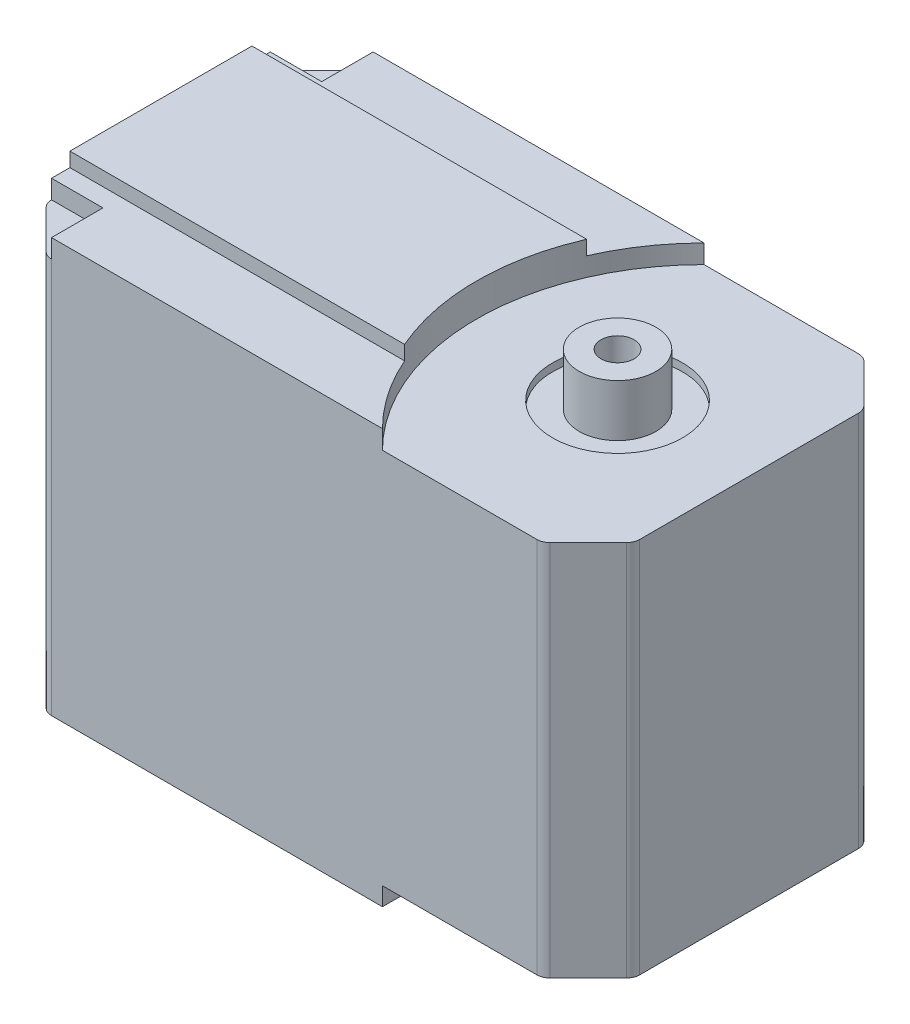
from build123d import *

# Parameters (mm, degrees)
IZIM1_W                      = 45.23
IZIM1_H                      = 24.73
Y_KSEKLIK_EKSTR_ZYON1_DEPTH  = 29
PAH1_SIZE                    = 3.54
RADYUS1_R                    = 1
IZIM3_R                      = 5
KES_EKSTR_ZYON1_DEPTH        = 0.6
IZIM4_R                      = 2.95
Y_KSEKLIK_EKSTR_ZYON2_DEPTH  = 4
IZIM5_R                      = 1.275
KES_EKSTR_ZYON2_DEPTH        = 8
Y_KSEKLIK_EKSTR_ZYON3_DEPTH  = 1.44
Y_KSEKLIK_EKSTR_ZYON4_DEPTH  = 1.1
IZIM8_R                      = 3
IZIM8_R_2                    = 1.2
Y_KSEKLIK_EKSTR_ZYON5_DEPTH  = 4.1
Y_KSEKLIK_EKSTR_ZYON6_DEPTH  = 1.4
IZIM10_W                     = 10
IZIM10_H                     = 18.55
Y_KSEKLIK_EKSTR_ZYON7_DEPTH  = 1.83
Y_KSEKLIK_EKSTR_ZYON8_DEPTH  = 18.55
IZIM12_W                     = 4.8
IZIM12_H                     = 19.53
KES_EKSTR_ZYON3_DEPTH        = 9.38
IZIM13_W                     = 0.7
IZIM13_H                     = 0.7
Y_KSEKLIK_EKSTR_ZYON9_DEPTH  = 3.59
IZIM14_W                     = 4.8
IZIM14_H                     = 9.807097864
IZIM14_W_2                   = 3.4
IZIM14_H_2                   = 8.407097864
IZIM14_H_3                   = 9.522902136
IZIM14_H_4                   = 8.122902136
Y_KSEKLIK_EKSTR_ZYON10_DEPTH = 4.59


with BuildPart() as part:
    # Çizim1 → Yükseklik-Ekstrüzyon1 (new body)
    with BuildSketch(Plane(origin=(0, 0, 0), x_dir=(1, 0, 0), z_dir=(0, 1, 0))):
        Rectangle(IZIM1_W, IZIM1_H)
    extrude(amount=Y_KSEKLIK_EKSTR_ZYON1_DEPTH)

    # Pah1
    pah1_edges = [part.edges().sort_by_distance(p)[0] for p in [
        (-22.615, 14.5, 12.365),
        (22.615, 14.5, 12.365),
        (22.615, 14.5, -12.365),
        (-22.615, 14.5, -12.365),
    ]]
    chamfer(pah1_edges, length=PAH1_SIZE)

    # Radyus1
    radyus1_edges = [part.edges().sort_by_distance(p)[0] for p in [
        (-22.615, 14.5, 8.825),
        (-22.615, 14.5, -8.825),
        (19.075, 14.5, -12.365),
        (-19.075, 14.5, -12.365),
        (19.075, 14.5, 12.365),
        (-19.075, 14.5, 12.365),
        (22.615, 14.5, 8.825),
        (22.615, 14.5, -8.825),
    ]]
    fillet(radyus1_edges, radius=RADYUS1_R)

    # Çizim3 → Kes-Ekstrüzyon1 (cut)
    with BuildSketch(Plane(origin=(0, 29, 0), x_dir=(1, 0, 0), z_dir=(0, 1, 0))):
        with Locations((12.5, 0)):
            Circle(IZIM3_R)
    extrude(amount=-KES_EKSTR_ZYON1_DEPTH, mode=Mode.SUBTRACT)

    # Çizim4 → Yükseklik-Ekstrüzyon2 (add)
    with BuildSketch(Plane(origin=(0, 28.4, 0), x_dir=(1, 0, 0), z_dir=(0, 1, 0))):
        with Locations((12.5, 0)):
            Circle(IZIM4_R)
    extrude(amount=Y_KSEKLIK_EKSTR_ZYON2_DEPTH)

    # Çizim5 → Kes-Ekstrüzyon2 (cut)
    with BuildSketch(Plane(origin=(0, 32.4, 0), x_dir=(1, 0, 0), z_dir=(0, 1, 0))):
        with Locations((12.5, 0)):
            Circle(IZIM5_R)
    extrude(amount=-KES_EKSTR_ZYON2_DEPTH, mode=Mode.SUBTRACT)

    # Çizim6 → Yükseklik-Ekstrüzyon3 (add)
    with BuildSketch(Plane(origin=(0, 29, 0), x_dir=(1, 0, 0), z_dir=(0, 1, 0))):
        with BuildLine():
            Line((6.785, -12.365), (-18.660786438, -12.365))
            Line((-18.660786438, -12.365), (-18.660786438, -8.410786438))
            Line((-18.660786438, -8.410786438), (-22.615, -8.410786438))
            Line((-22.615, -8.410786438), (-22.615, 8.410786438))
            Line((-22.615, 8.410786438), (-18.660786438, 8.410786438))
            Line((-18.660786438, 8.410786438), (-18.660786438, 12.365))
            Line((-18.660786438, 12.365), (6.785, 12.365))
            ThreePointArc((6.785, 12.365), (1.663249301, 0), (6.785, -12.365))
        make_face()
    extrude(amount=Y_KSEKLIK_EKSTR_ZYON3_DEPTH)

    # Çizim7 → Yükseklik-Ekstrüzyon4 (add)
    with BuildSketch(Plane(origin=(0, 30.44, 0), x_dir=(1, 0, 0), z_dir=(0, 1, 0))):
        with BuildLine():
            Line((-22.615, 7), (3.125442284, 7))
            ThreePointArc((3.125442284, 7), (1.663249301, 0), (3.125442284, -7))
            Line((3.125442284, -7), (-22.615, -7))
            Line((-22.615, -7), (-22.615, 7))
        make_face()
    extrude(amount=Y_KSEKLIK_EKSTR_ZYON4_DEPTH)

    # Çizim8 → Yükseklik-Ekstrüzyon5 (add)
    with BuildSketch(Plane.XZ):
        with Locations((12.5, 0)):
            Circle(IZIM8_R)
        with Locations((12.5, 0)):
            Circle(IZIM8_R_2, mode=Mode.SUBTRACT)
    extrude(amount=Y_KSEKLIK_EKSTR_ZYON5_DEPTH)

    # Çizim9 → Yükseklik-Ekstrüzyon6 (add)
    with BuildSketch(Plane.XZ):
        with BuildLine():
            Line((6.785, 12.365), (6.785, 9.165))
            Line((6.785, 9.165), (3.735, 6.615))
            Line((3.735, 6.615), (0.535, 6.615))
            Line((0.535, 6.615), (0.535, 9.765))
            Line((0.535, 9.765), (-4.265, 9.765))
            Line((-4.265, 9.765), (-4.265, -9.765))
            Line((-4.265, -9.765), (0.535, -9.765))
            Line((0.535, -9.765), (0.535, -6.615))
            Line((0.535, -6.615), (3.735, -6.615))
            Line((3.735, -6.615), (6.785, -9.165))
            Line((6.785, -9.165), (6.785, -12.365))
            Line((6.785, -12.365), (-18.660786438, -12.365))
            ThreePointArc((-18.660786438, -12.365), (-19.04346987, -12.288879533), (-19.367893219, -12.072106781))
            Line((-19.367893219, -12.072106781), (-22.322106781, -9.117893219))
            ThreePointArc((-22.322106781, -9.117893219), (-22.538879533, -8.79346987), (-22.615, -8.410786438))
            Line((-22.615, -8.410786438), (-22.615, 8.410786438))
            ThreePointArc((-22.615, 8.410786438), (-22.538879533, 8.79346987), (-22.322106781, 9.117893219))
            Line((-22.322106781, 9.117893219), (-19.367893219, 12.072106781))
            ThreePointArc((-19.367893219, 12.072106781), (-19.04346987, 12.288879533), (-18.660786438, 12.365))
            Line((-18.660786438, 12.365), (6.785, 12.365))
        make_face()
    extrude(amount=Y_KSEKLIK_EKSTR_ZYON6_DEPTH)

    # Çizim10 → Yükseklik-Ekstrüzyon7 (add)
    with BuildSketch(Plane.XZ.offset(1.4)):
        with Locations((-12.665, 0)):
            Rectangle(IZIM10_W, IZIM10_H)
    extrude(amount=Y_KSEKLIK_EKSTR_ZYON7_DEPTH)

    # Çizim11 → Yükseklik-Ekstrüzyon8 (add)
    with BuildSketch(Plane(origin=(0, 0, -9.275), x_dir=(-1, 0, 0), z_dir=(0, 0, -1))):
        Polygon((7.665, -3.23), (7.665, -1.4), (4.265, -1.4), align=None)
    extrude(amount=-Y_KSEKLIK_EKSTR_ZYON8_DEPTH)

    # Çizim12 → Kes-Ekstrüzyon3 (cut)
    with BuildSketch(Plane.XZ):
        with Locations((-1.865, 0)):
            Rectangle(IZIM12_W, IZIM12_H)
    extrude(amount=-KES_EKSTR_ZYON3_DEPTH, mode=Mode.SUBTRACT)

    # Çizim13 → Yükseklik-Ekstrüzyon9 (add)
    with BuildSketch(Plane.XZ.offset(-9.38)):
        with Locations((-1.165, 4.8825)):
            Rectangle(IZIM13_W, IZIM13_H)
        with Locations((-1.165, 6.9725)):
            Rectangle(IZIM13_W, IZIM13_H)
        with Locations((-1.165, 2.7925)):
            Rectangle(IZIM13_W, IZIM13_H)
        with Locations((-1.165, -2.7925)):
            Rectangle(IZIM13_W, IZIM13_H)
        with Locations((-1.165, -6.9725)):
            Rectangle(IZIM13_W, IZIM13_H)
        with Locations((-1.165, -4.8825)):
            Rectangle(IZIM13_W, IZIM13_H)
    extrude(amount=Y_KSEKLIK_EKSTR_ZYON9_DEPTH)

    # Çizim14 → Yükseklik-Ekstrüzyon10 (add)
    with BuildSketch(Plane.XZ.offset(-9.38)):
        with Locations((-1.865, 4.861451068)):
            Rectangle(IZIM14_W, IZIM14_H)
        with Locations((-1.865, 4.861451068)):
            Rectangle(IZIM14_W_2, IZIM14_H_2, mode=Mode.SUBTRACT)
        with Locations((-1.865, -5.003548932)):
            Rectangle(IZIM14_W, IZIM14_H_3)
        with Locations((-1.865, -5.003548932)):
            Rectangle(IZIM14_W_2, IZIM14_H_4, mode=Mode.SUBTRACT)
    extrude(amount=Y_KSEKLIK_EKSTR_ZYON10_DEPTH)


solid = part.part
